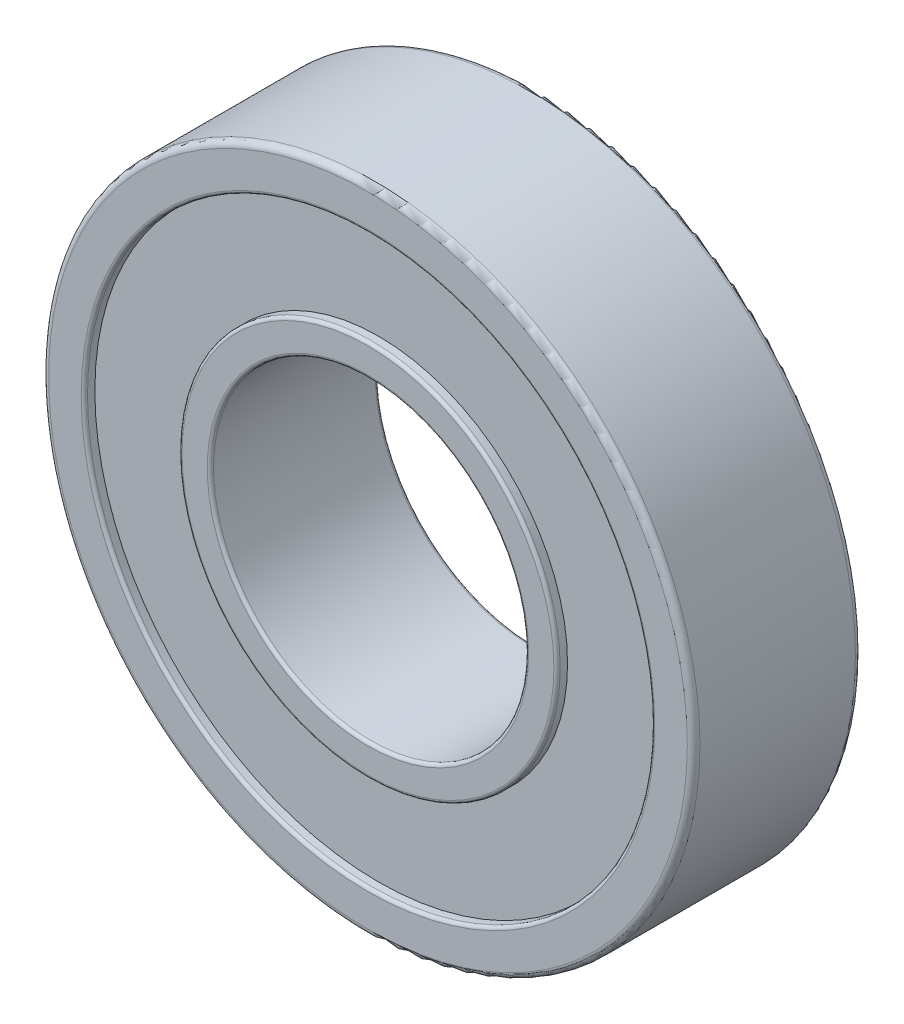
from build123d import *

# Parameters (mm, degrees)
IZIM1_R                     = 31
IZIM1_R_2                   = 15
Y_KSEKLIK_EKSTR_ZYON1_DEPTH = 16
IZIM2_R                     = 27
IZIM2_R_2                   = 18
KES_EKSTR_ZYON1_DEPTH       = 1
IZIM3_R                     = 27
IZIM3_R_2                   = 18
KES_EKSTR_ZYON2_DEPTH       = 1
RADYUS1_R                   = 0.6
RADYUS2_R                   = 0.3


with BuildPart() as part:
    # Çizim1 → Yükseklik-Ekstrüzyon1 (new body)
    with BuildSketch(Plane.XY):
        Circle(IZIM1_R)
        Circle(IZIM1_R_2, mode=Mode.SUBTRACT)
    extrude(amount=Y_KSEKLIK_EKSTR_ZYON1_DEPTH)

    # Çizim2 → Kes-Ekstrüzyon1 (cut)
    with BuildSketch(Plane(origin=(0, 0, 0), x_dir=(-1, 0, 0), z_dir=(0, 0, -1))):
        Circle(IZIM2_R)
        Circle(IZIM2_R_2, mode=Mode.SUBTRACT)
    extrude(amount=-KES_EKSTR_ZYON1_DEPTH, mode=Mode.SUBTRACT)

    # Çizim3 → Kes-Ekstrüzyon2 (cut)
    with BuildSketch(Plane.XY.offset(16)):
        Circle(IZIM3_R)
        Circle(IZIM3_R_2, mode=Mode.SUBTRACT)
    extrude(amount=-KES_EKSTR_ZYON2_DEPTH, mode=Mode.SUBTRACT)

    # Radyus1
    radyus1_edges = [part.edges().sort_by_distance(p)[0] for p in [
        (-31, 0, 0),
        (-31, 0, 16),
    ]]
    fillet(radyus1_edges, radius=RADYUS1_R)

    # Radyus2
    radyus2_edges = [part.edges().sort_by_distance(p)[0] for p in [
        (27, 0, 0),
        (18, 0, 0),
        (-27, 0, 16),
        (-18, 0, 16),
        (-15, 0, 0),
        (-15, 0, 16),
    ]]
    fillet(radyus2_edges, radius=RADYUS2_R)


solid = part.part
